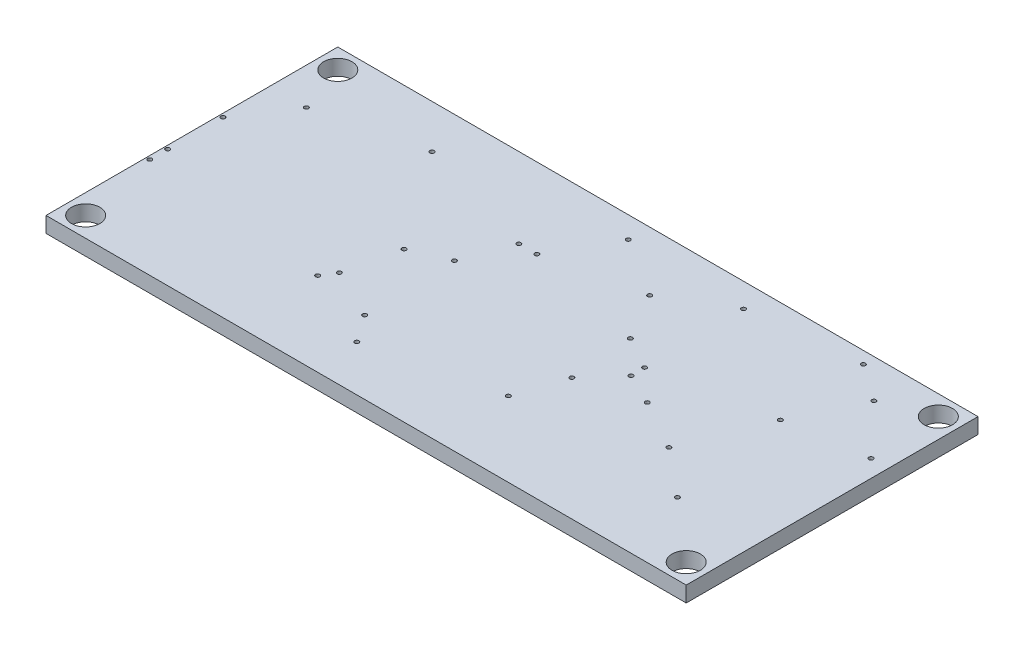
from build123d import *

# Parameters (mm, degrees)
SKETCH1_W           = 45.2
SKETCH1_H           = 20.6
BOSS_EXTRUDE1_DEPTH = 1.1
SKETCH18_R          = 1
CUT_EXTRUDE4_DEPTH  = 2.1
SKETCH30_R          = 0.15
CUT_EXTRUDE6_DEPTH  = 1.1


with BuildPart() as part:
    # Sketch1 → Boss-Extrude1 (new body)
    with BuildSketch(Plane(origin=(0, 0, 0), x_dir=(1, 0, 0), z_dir=(0, 1, 0))):
        Rectangle(SKETCH1_W, SKETCH1_H)
    extrude(amount=BOSS_EXTRUDE1_DEPTH)

    # Sketch18 → Cut-Extrude4 (cut, through all)
    with BuildSketch(Plane(origin=(0, 1.1, 0), x_dir=(1, 0, 0), z_dir=(0, 1, 0))):
        with Locations((-21.2, -8.9)):
            Circle(SKETCH18_R)
        with Locations((21.2, 8.9)):
            Circle(SKETCH18_R)
    cut_extrude4 = extrude(amount=-CUT_EXTRUDE4_DEPTH, mode=Mode.SUBTRACT)

    # Sketch30 → Cut-Extrude6 (cut)
    with BuildSketch(Plane.XZ):
        with Locations((-9.333130036, 4.387708864)):
            Circle(SKETCH30_R)
        with Locations((-8.744545033, 3.449056667)):
            Circle(SKETCH30_R)
        with Locations((4.759894179, 5.015066472)):
            Circle(SKETCH30_R)
        with Locations((16.922953898, 5.247379324)):
            Circle(SKETCH30_R)
        with Locations((7.830601522, -1.527883327)):
            Circle(SKETCH30_R)
        with Locations((7.85211857, -0.548857679)):
            Circle(SKETCH30_R)
        with Locations((5.549794517, -2.808147637)):
            Circle(SKETCH30_R)
        with Locations((5.883308749, 1.656639662)):
            Circle(SKETCH30_R)
        with Locations((15.827488091, -3.115541656)):
            Circle(SKETCH30_R)
        with Locations((21.375936622, -3.969149123)):
            Circle(SKETCH30_R)
        with Locations((17.961506757, -7.584427803)):
            Circle(SKETCH30_R)
        with Locations((15.35602841, -9.449889168)):
            Circle(SKETCH30_R)
        with Locations((3.599221967, -6.119367867)):
            Circle(SKETCH30_R)
        with Locations((7.740262146, -8.603991974)):
            Circle(SKETCH30_R)
        with Locations((-0.570878142, -8.77835156)):
            Circle(SKETCH30_R)
        with Locations((-2.901654637, -4.656320507)):
            Circle(SKETCH30_R)
        with Locations((-4.176494296, -4.656320507)):
            Circle(SKETCH30_R)
        with Locations((-5.415606667, -1.349023089)):
            Circle(SKETCH30_R)
        with Locations((-7.901413801, -0.278896563)):
            Circle(SKETCH30_R)
        with Locations((-5.254994429, 5.1458063)):
            Circle(SKETCH30_R)
        with Locations((-3.895298753, 7.064281021)):
            Circle(SKETCH30_R)
        with Locations((13.574528056, 2.494833551)):
            Circle(SKETCH30_R)
        with Locations((10.060923878, 0.512200964)):
            Circle(SKETCH30_R)
        with Locations((-12.870283271, -7.223609825)):
            Circle(SKETCH30_R)
        with Locations((-20.003938885, -5.491150605)):
            Circle(SKETCH30_R)
        with Locations((-22.357061828, 3.218671023)):
            Circle(SKETCH30_R)
        with Locations((-22.357061828, 1.95517224)):
            Circle(SKETCH30_R)
        with Locations((-22.357061828, -1.948730844)):
            Circle(SKETCH30_R)
    extrude(amount=-CUT_EXTRUDE6_DEPTH, mode=Mode.SUBTRACT)

    # Mirror1: Cut-Extrude4 across plane
    add(cut_extrude4.mirror(Plane(origin=(0, 0, 0), x_dir=(0, 0, 1), z_dir=(1, 0, 0))), mode=Mode.SUBTRACT)


solid = part.part
